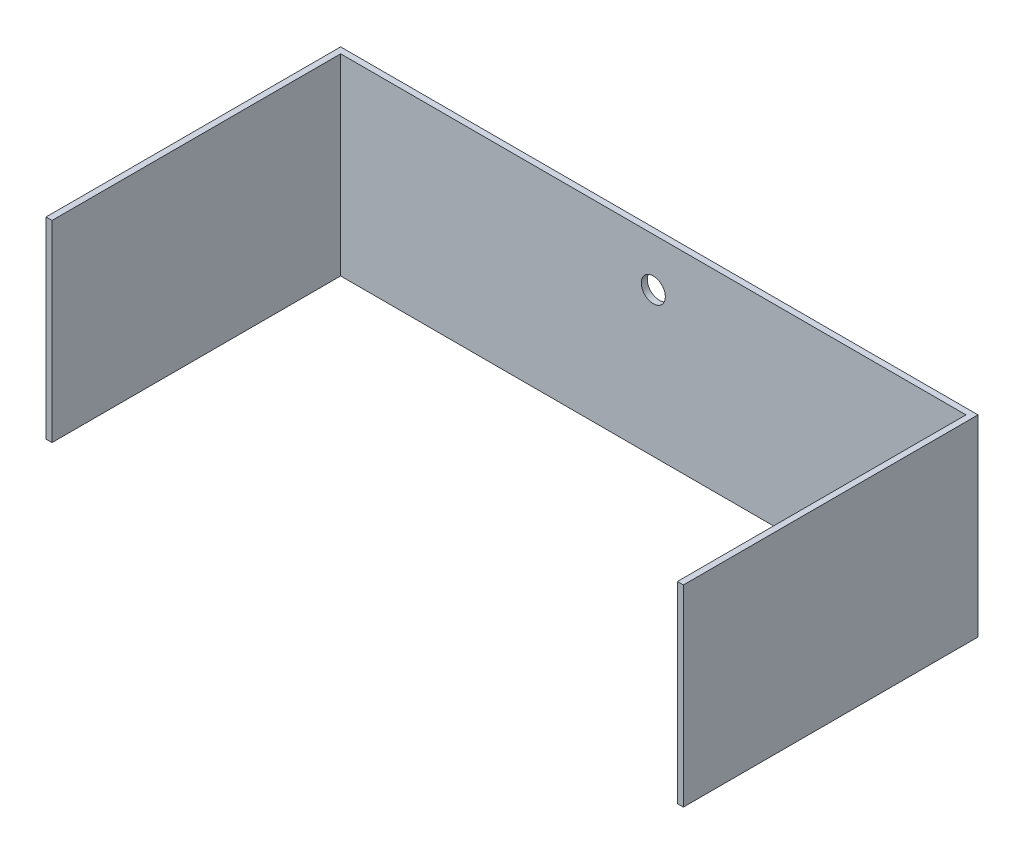
from build123d import *

# Parameters (mm, degrees)
BOSS_EXTRUDE1_DEPTH = 101.6
CUT_EXTRUDE1_REACH  = 157.575
SKETCH2_R           = 6.35


with BuildPart() as part:
    # Sketch1 → Boss-Extrude1 (new body)
    with BuildSketch(Plane(origin=(0, 0, 0), x_dir=(1, 0, 0), z_dir=(0, 1, 0))):
        Polygon((0, 0), (0, 152.4), (330.2, 152.4), (330.2, 0), (333.375, 0), (333.375, 155.575), (-3.175, 155.575), (-3.175, 0), align=None)
    extrude(amount=BOSS_EXTRUDE1_DEPTH)

    # Sketch2 → Cut-Extrude1 (cut, up to next)
    with BuildSketch(Plane(origin=(0, 0, -155.575), x_dir=(-1, 0, 0), z_dir=(0, 0, -1)), mode=Mode.PRIVATE) as cut_extrude1_sk1:
        with Locations((-165.1, 76.2)):
            Circle(SKETCH2_R)
    cut_extrude1_tool1 = extrude(cut_extrude1_sk1.sketch, amount=-CUT_EXTRUDE1_REACH, mode=Mode.PRIVATE) & part.part
    add(cut_extrude1_tool1.solids().sort_by_distance((165.1, 76.2, -155.575))[0], mode=Mode.SUBTRACT)


solid = part.part
